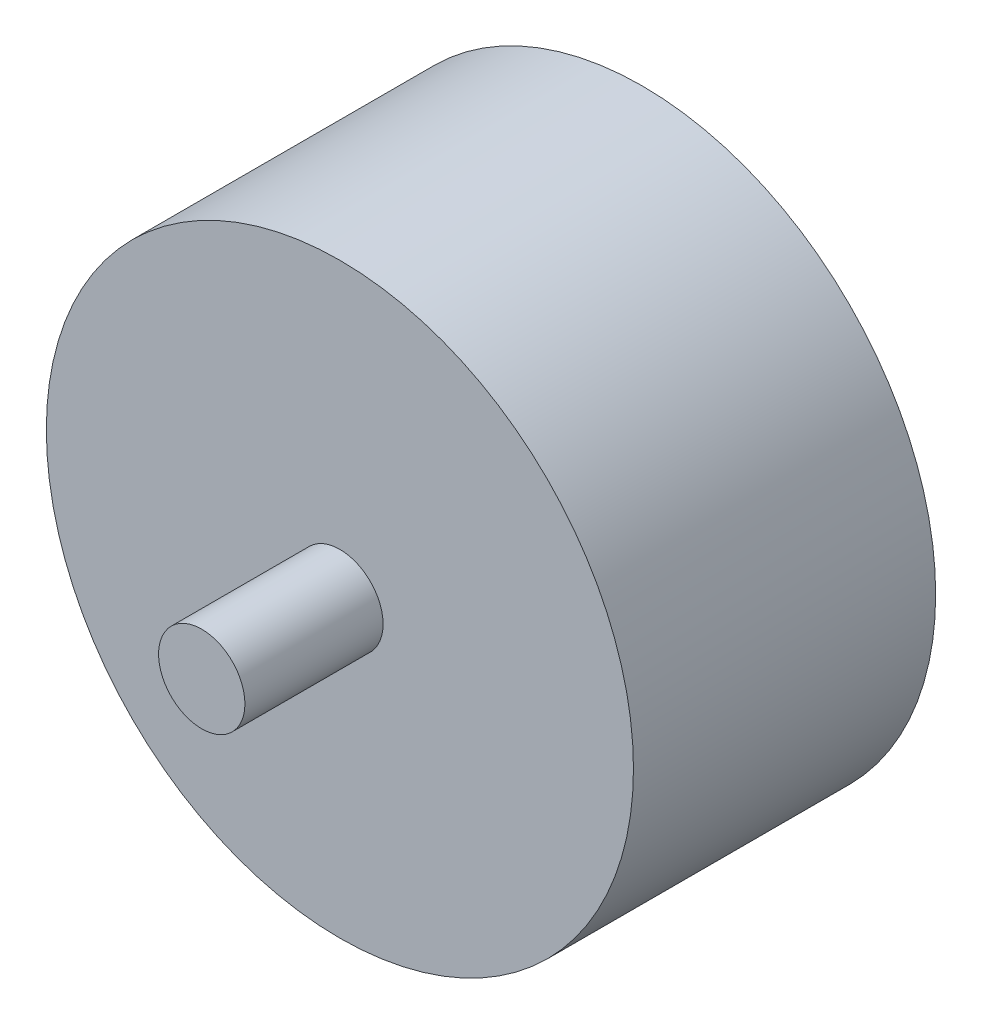
from build123d import *

# Parameters (mm, degrees)
SKETCH1_R           = 17
BOSS_EXTRUDE1_DEPTH = 25.5
SKETCH2_R           = 17
SKETCH2_R_2         = 2.5
CUT_EXTRUDE1_DEPTH  = 8


with BuildPart() as part:
    # Sketch1 → Boss-Extrude1 (new body)
    with BuildSketch(Plane.XY):
        Circle(SKETCH1_R)
    extrude(amount=BOSS_EXTRUDE1_DEPTH)

    # Sketch2 → Cut-Extrude1 (cut)
    with BuildSketch(Plane.XY.offset(25.5)):
        Circle(SKETCH2_R)
        Circle(SKETCH2_R_2, mode=Mode.SUBTRACT)
    extrude(amount=-CUT_EXTRUDE1_DEPTH, mode=Mode.SUBTRACT)


solid = part.part
